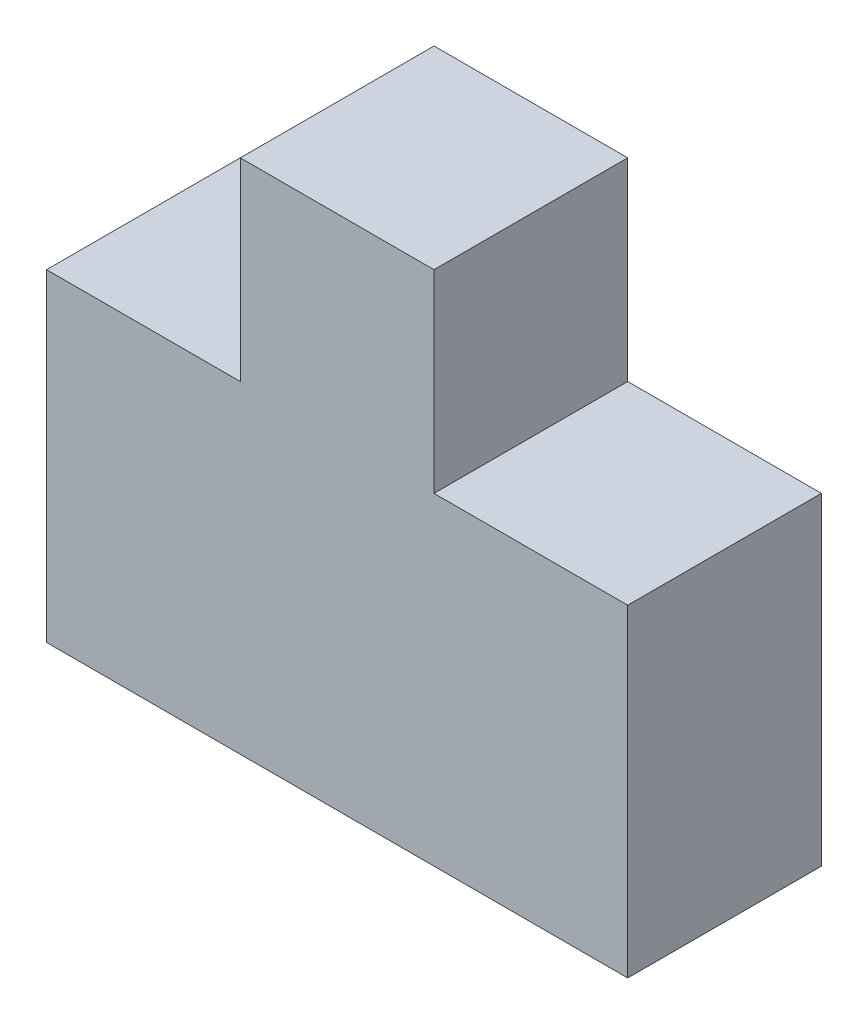
from build123d import *

# Parameters (mm, degrees)
BOSS_EXTRUDE1_DEPTH = 30


with BuildPart() as part:
    # Sketch2 → Boss-Extrude1 (new body)
    with BuildSketch(Plane.XY):
        Polygon((-45, 0), (45, 0), (45, 50), (15, 50), (15, 80), (-15, 80), (-15, 50), (-45, 50), align=None)
    extrude(amount=BOSS_EXTRUDE1_DEPTH)


solid = part.part
